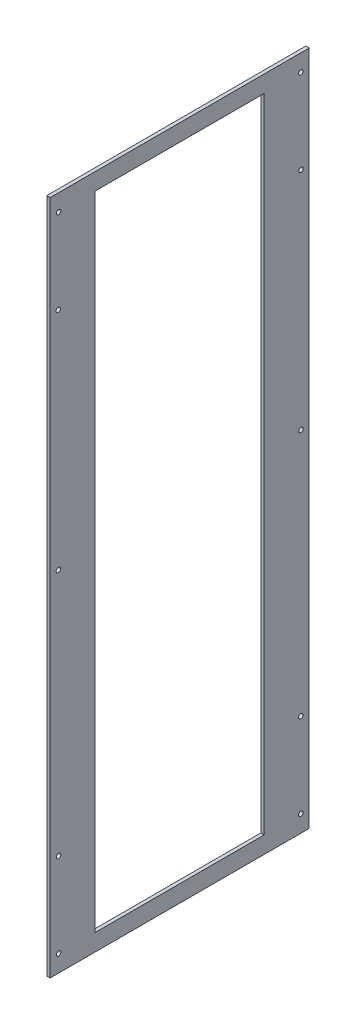
from build123d import *

# Parameters (mm, degrees)
SKETCH_1_W      = 230
SKETCH_1_H      = 600
SKETCH_1_R      = 2
SKETCH_1_W_2    = 150
SKETCH_1_H_2    = 570
EXTRUDE_1_DEPTH = 3


with BuildPart() as part:
    # 草图1 → 凸台-拉伸1 (new body)
    with BuildSketch(Plane(origin=(0, 0, 0), x_dir=(0, 0, -1), z_dir=(1, 0, 0))):
        Rectangle(SKETCH_1_W, SKETCH_1_H)
        with Locations((-107.5, 285)):
            Circle(SKETCH_1_R, mode=Mode.SUBTRACT)
        with Locations((-107.698004772, 210)):
            Circle(SKETCH_1_R, mode=Mode.SUBTRACT)
        with Locations((-107.5, -210)):
            Circle(SKETCH_1_R, mode=Mode.SUBTRACT)
        with Locations((-107.5, -285)):
            Circle(SKETCH_1_R, mode=Mode.SUBTRACT)
        with Locations((-107.698004772, 10)):
            Circle(SKETCH_1_R, mode=Mode.SUBTRACT)
        with Locations((107.5, -285)):
            Circle(SKETCH_1_R, mode=Mode.SUBTRACT)
        with Locations((107.5, -210)):
            Circle(SKETCH_1_R, mode=Mode.SUBTRACT)
        with Locations((107.698004772, 210)):
            Circle(SKETCH_1_R, mode=Mode.SUBTRACT)
        with Locations((107.5, 285)):
            Circle(SKETCH_1_R, mode=Mode.SUBTRACT)
        with Locations((107.698004772, 10)):
            Circle(SKETCH_1_R, mode=Mode.SUBTRACT)
        Rectangle(SKETCH_1_W_2, SKETCH_1_H_2, mode=Mode.SUBTRACT)
    extrude(amount=EXTRUDE_1_DEPTH)


solid = part.part
